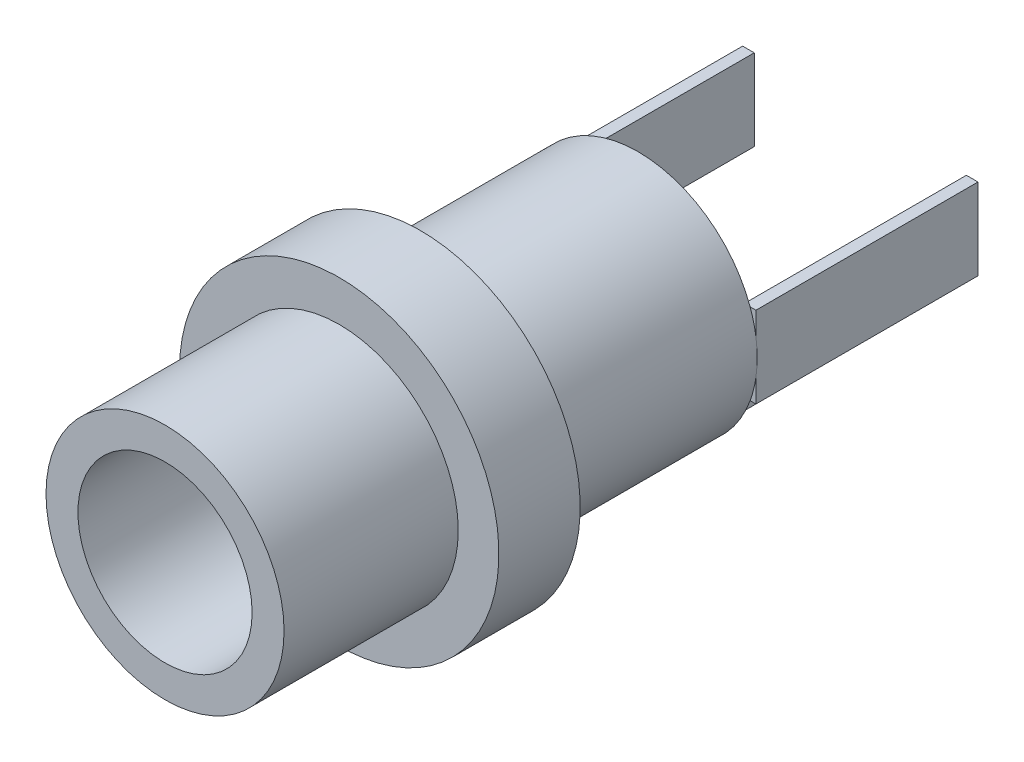
from build123d import *

# Parameters (mm, degrees)
SKETCH1_R           = 4.1
SKETCH1_R_2         = 3
BOSS_EXTRUDE1_DEPTH = 6
SKETCH2_R           = 5.5
BOSS_EXTRUDE2_DEPTH = 2.8
SKETCH3_R           = 4.1
BOSS_EXTRUDE3_DEPTH = 7.5
SKETCH4_W           = 0.4
SKETCH4_H           = 2.8
SKETCH4_W_2         = 2.8
SKETCH4_H_2         = 0.4
EXTRUDE_THIN1_DEPTH = 7.65


with BuildPart() as part:
    # Sketch1 → Boss-Extrude1 (new body)
    with BuildSketch(Plane.XY):
        Circle(SKETCH1_R)
        Circle(SKETCH1_R_2, mode=Mode.SUBTRACT)
    extrude(amount=-BOSS_EXTRUDE1_DEPTH)

    # Sketch2 → Boss-Extrude2 (add)
    with BuildSketch(Plane(origin=(0, 0, -6), x_dir=(-1, 0, 0), z_dir=(0, 0, -1))):
        Circle(SKETCH2_R)
    extrude(amount=BOSS_EXTRUDE2_DEPTH)

    # Sketch3 → Boss-Extrude3 (add)
    with BuildSketch(Plane(origin=(0, 0, -8.8), x_dir=(-1, 0, 0), z_dir=(0, 0, -1))):
        Circle(SKETCH3_R)
    extrude(amount=BOSS_EXTRUDE3_DEPTH)

    # Sketch4 → Extrude-Thin1 (add)
    with BuildSketch(Plane(origin=(0, 0, -16.3), x_dir=(-1, 0, 0), z_dir=(0, 0, -1))):
        with Locations((-3.853569774, 0)):
            Rectangle(SKETCH4_W, SKETCH4_H)
        with Locations((0, -3.853569774)):
            Rectangle(SKETCH4_W_2, SKETCH4_H_2)
        with Locations((3.853569774, 0)):
            Rectangle(SKETCH4_W, SKETCH4_H)
    extrude(amount=EXTRUDE_THIN1_DEPTH)


solid = part.part
